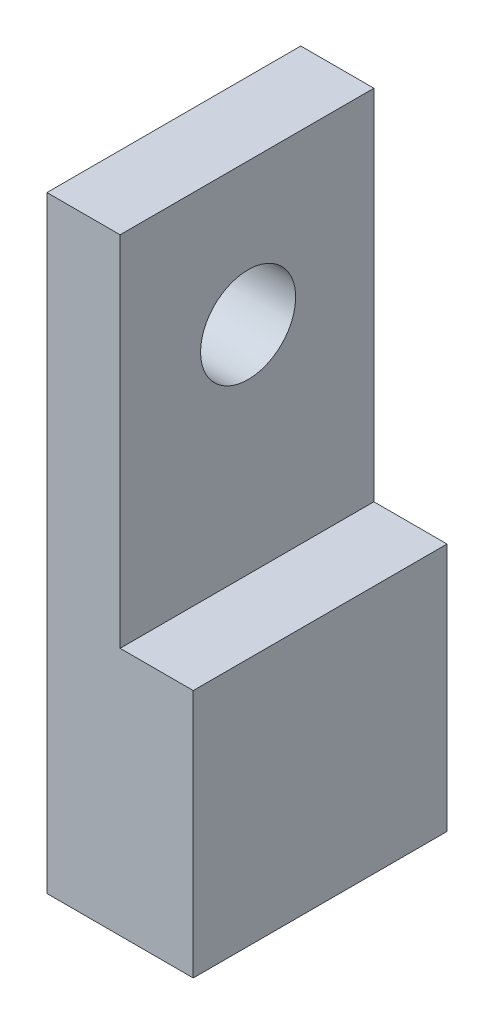
from build123d import *

# Parameters (mm, degrees)
SKETCH1_W                 = 20
SKETCH1_H                 = 34.7
BOSS_EXTRUDE1_DEPTH       = 83
CUT_EXTRUDE2_REACH        = 36.7
SKETCH3_W                 = 10
SKETCH3_H                 = 48.965000852
CUT_EXTRUDE3_REACH        = 22
SKETCH4_R                 = 6.5
M3X0_5_TAPPED_HOLE1_D     = 2.5
M3X0_5_TAPPED_HOLE1_DEPTH = 7.5
M3X0_5_TAPPED_HOLE1_TIP   = 0.751075774
M6X1_0_TAPPED_HOLE1_D     = 5
M6X1_0_TAPPED_HOLE1_DEPTH = 15
M6X1_0_TAPPED_HOLE1_TIP   = 1.502151548
F_4_0MM_DOWEL_HOLE1_D     = 4
F_4_0MM_DOWEL_HOLE1_DEPTH = 5.2
F_4_0MM_DOWEL_HOLE1_TIP   = 1.201721238


with BuildPart() as part:
    # Sketch1 → Boss-Extrude1 (new body)
    with BuildSketch(Plane(origin=(0, 0, 0), x_dir=(1, 0, 0), z_dir=(0, 1, 0))):
        with Locations((5.656892123, -5.553125)):
            Rectangle(SKETCH1_W, SKETCH1_H)
    extrude(amount=BOSS_EXTRUDE1_DEPTH)

    # Sketch3 → Cut-Extrude2 (cut, up to next)
    with BuildSketch(Plane(origin=(0, 0, -11.796875), x_dir=(-1, 0, 0), z_dir=(0, 0, -1)), mode=Mode.PRIVATE) as cut_extrude2_sk1:
        with Locations((-10.656892123, 58.517499574)):
            Rectangle(SKETCH3_W, SKETCH3_H)
    cut_extrude2_tool1 = extrude(cut_extrude2_sk1.sketch, amount=-CUT_EXTRUDE2_REACH, mode=Mode.PRIVATE) & part.part
    add(cut_extrude2_tool1.solids().sort_by_distance((10.656892, 58.5175, -11.796875))[0], mode=Mode.SUBTRACT)

    # Sketch4 → Cut-Extrude3 (cut, up to next)
    with BuildSketch(Plane.ZY.offset(4.343107877), mode=Mode.PRIVATE) as cut_extrude3_sk1:
        with Locations((5.403125, 63.609645263)):
            Circle(SKETCH4_R)
    cut_extrude3_tool1 = extrude(cut_extrude3_sk1.sketch, amount=-CUT_EXTRUDE3_REACH, mode=Mode.PRIVATE) & part.part
    add(cut_extrude3_tool1.solids().sort_by_distance((-4.343108, 63.609645, 5.403125))[0], mode=Mode.SUBTRACT)

    # M3x0.5 Tapped Hole1
    with Locations(Plane.ZY.offset(4.343107877)):
        with Locations((-7.096875, 51.109645263), (17.903125, 51.109645263), (17.903125, 76.109645263), (-7.096875, 76.109645263)):
            Hole(M3X0_5_TAPPED_HOLE1_D / 2, depth=M3X0_5_TAPPED_HOLE1_DEPTH)
            with Locations((0, 0, -(M3X0_5_TAPPED_HOLE1_DEPTH + M3X0_5_TAPPED_HOLE1_TIP / 2))):  # 118° drill point
                Cone(0, M3X0_5_TAPPED_HOLE1_D / 2, M3X0_5_TAPPED_HOLE1_TIP, mode=Mode.SUBTRACT)

    # M6x1.0 Tapped Hole1
    with Locations(Plane(origin=(0, 0, 0), x_dir=(-1, 0, 0), z_dir=(0, -1, 0))):
        with Locations((-5.656892123, -5.553125)):
            Hole(M6X1_0_TAPPED_HOLE1_D / 2, depth=M6X1_0_TAPPED_HOLE1_DEPTH)
            with Locations((0, 0, -(M6X1_0_TAPPED_HOLE1_DEPTH + M6X1_0_TAPPED_HOLE1_TIP / 2))):  # 118° drill point
                Cone(0, M6X1_0_TAPPED_HOLE1_D / 2, M6X1_0_TAPPED_HOLE1_TIP, mode=Mode.SUBTRACT)

    # Ø4.0mm Dowel Hole1
    with Locations(Plane(origin=(0, 0, 0), x_dir=(-1, 0, 0), z_dir=(0, -1, 0))):
        with Locations((-5.656892123, -17.903125), (-5.656892123, 6.796875)):
            Hole(F_4_0MM_DOWEL_HOLE1_D / 2, depth=F_4_0MM_DOWEL_HOLE1_DEPTH)
            with Locations((0, 0, -(F_4_0MM_DOWEL_HOLE1_DEPTH + F_4_0MM_DOWEL_HOLE1_TIP / 2))):  # 118° drill point
                Cone(0, F_4_0MM_DOWEL_HOLE1_D / 2, F_4_0MM_DOWEL_HOLE1_TIP, mode=Mode.SUBTRACT)


solid = part.part
